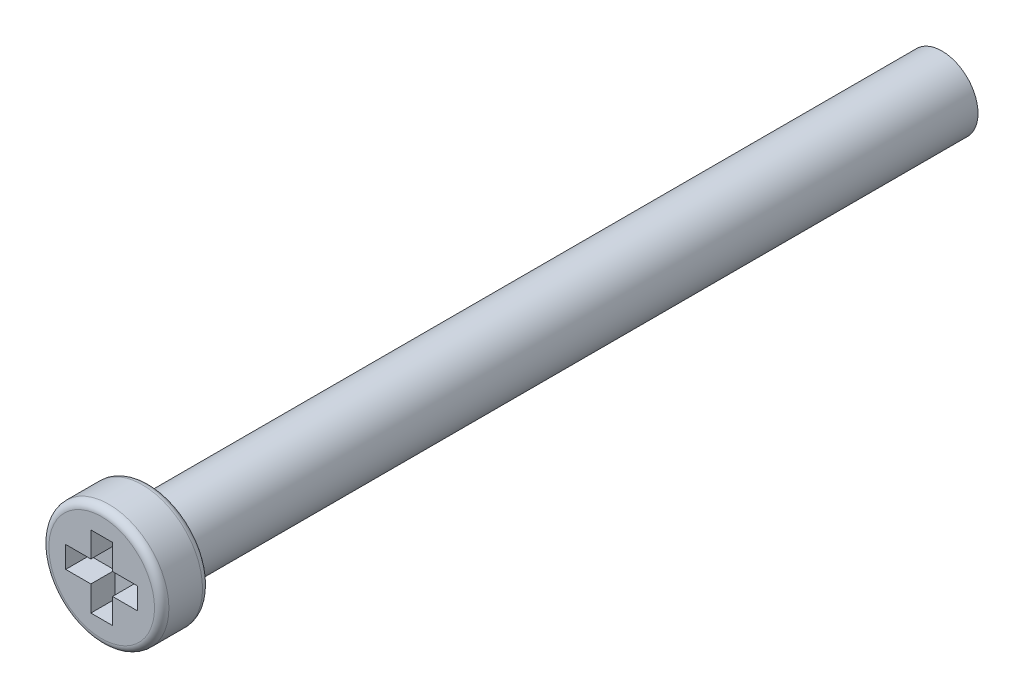
from build123d import *

# Parameters (mm, degrees)
SKETCH_1_R          = 2.5
EXTRUDE_1_DEPTH     = 2
SKETCH_2_R          = 1.5
EXTRUDE_2_DEPTH     = 33
FILLET_2_R          = 0.3
CUT_EXTRUDE_1_DEPTH = 1
FILLET_1_R          = 0.1


with BuildPart() as part:
    # Эскиз1 → Бобышка-Вытянуть1 (new body)
    with BuildSketch(Plane.XY):
        Circle(SKETCH_1_R)
    extrude(amount=EXTRUDE_1_DEPTH)

    # Эскиз2 → Бобышка-Вытянуть2 (add)
    with BuildSketch(Plane(origin=(0, 0, 0), x_dir=(-1, 0, 0), z_dir=(0, 0, -1))):
        Circle(SKETCH_2_R)
    extrude(amount=EXTRUDE_2_DEPTH)

    # Скругление2
    fillet_2_edges = [part.edges().sort_by_distance(p)[0] for p in [
        (-2.5, 0, 0),
        (-2.5, 0, 2),
    ]]
    fillet(fillet_2_edges, radius=FILLET_2_R)

    # Эскиз3 → Вырез-Вытянуть1 (cut)
    with BuildSketch(Plane.XY.offset(2)):
        Polygon((-0.45, 1.5), (0.45, 1.5), (0.45, 0.45), (1.5, 0.45), (1.5, -0.45), (0.45, -0.45), (0.45, -1.5), (-0.45, -1.5), (-0.45, -0.45), (-1.5, -0.45), (-1.5, 0.45), (-0.45, 0.45), align=None)
    extrude(amount=-CUT_EXTRUDE_1_DEPTH, mode=Mode.SUBTRACT)

    # Скругление1
    fillet_1_edges = [part.edges().sort_by_distance(p)[0] for p in [
        (1.5, 0, 0),
    ]]
    fillet(fillet_1_edges, radius=FILLET_1_R)


solid = part.part
